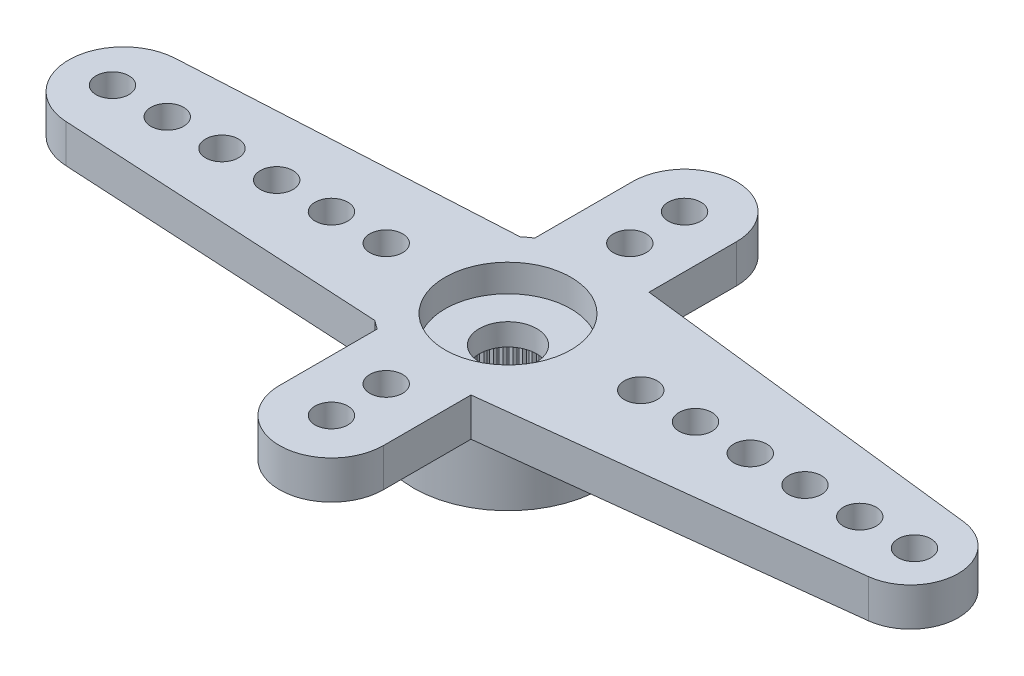
from build123d import *

# Parameters (mm, degrees)
RESSALTO_EXTRUS_O1_DEPTH = 1.4
ESBO_O2_R                = 3.45
RESSALTO_EXTRUS_O2_DEPTH = 2.4
FURO1_D                  = 1.2
PADR_O_LINEAR1_COUNT     = 6
PADR_O_LINEAR1_PITCH     = 2
RESSALTO_EXTRUS_O3_DEPTH = 1.4
FURO2_D                  = 1.2
PADR_O_LINEAR2_COUNT     = 6
PADR_O_LINEAR2_PITCH     = 2
RESSALTO_EXTRUS_O4_DEPTH = 1.4
FURO3_D                  = 1.2
PADR_O_LINEAR3_COUNT     = 2
PADR_O_LINEAR3_PITCH     = 2
PADR_OCIRCULAR1_COUNT    = 2
PADR_OCIRCULAR1_COPY_1_D = 1.2
FURO4_D                  = 4.95
FURO4_DEPTH              = 2
FURO5_D                  = 4.6
FURO5_DEPTH              = 1
FURO6_D                  = 2.1
RESSALTO_EXTRUS_O5_DEPTH = 2
PADR_OCIRCULAR2_COUNT    = 60


with BuildPart() as part:
    # Esboço1 → Ressalto-extrusão1 (new body)
    with BuildSketch(Plane(origin=(0, 0, 0), x_dir=(1, 0, 0), z_dir=(0, 1, 0))):
        with BuildLine():
            Line((-14.159121967, 1.99702088), (-2.209072203, 2.65))
            ThreePointArc((-2.209072203, 2.65), (3.45, 0), (-2.209072203, -2.65))
            Line((-2.209072203, -2.65), (-14.159121967, -1.99702088))
            ThreePointArc((-14.159121967, -1.99702088), (-16.05, 0), (-14.159121967, 1.99702088))
        make_face()
    extrude(amount=-RESSALTO_EXTRUS_O1_DEPTH)

    # Esboço2 → Ressalto-extrusão2 (add)
    with BuildSketch(Plane.XZ.offset(1.4)):
        Circle(ESBO_O2_R)
    extrude(amount=RESSALTO_EXTRUS_O2_DEPTH)

    # Furo1 (through all)
    with Locations(Plane(origin=(0, 0, 0), x_dir=(1, 0, 0), z_dir=(0, 1, 0))):
        with Locations((-14.45, 0)):
            furo1 = Hole(FURO1_D / 2)

    # Padrão linear1: Furo1 ×6
    with Locations(*[(i * PADR_O_LINEAR1_PITCH, 0, 0) for i in range(1, PADR_O_LINEAR1_COUNT)]):
        add(furo1, mode=Mode.SUBTRACT)

    # Esboço12 → Ressalto-extrusão3 (add)
    with BuildSketch(Plane(origin=(0, 0, 0), x_dir=(1, 0, 0), z_dir=(0, 1, 0))):
        with BuildLine():
            Line((0.398979592, 3.426852096), (14.902380952, 1.738258309))
            ThreePointArc((14.902380952, 1.738258309), (16.45, 0), (14.902380952, -1.738258309))
            Line((14.902380952, -1.738258309), (0.398979592, -3.426852096))
            ThreePointArc((0.398979592, -3.426852096), (3.45, 0), (0.398979592, 3.426852096))
        make_face()
    extrude(amount=-RESSALTO_EXTRUS_O3_DEPTH)

    # Furo2 (through all)
    with Locations(Plane(origin=(0, 0, 0), x_dir=(1, 0, 0), z_dir=(0, 1, 0))):
        with Locations((14.85, 0)):
            furo2 = Hole(FURO2_D / 2)

    # Padrão linear2: Furo2 ×6
    with Locations(*[(-i * PADR_O_LINEAR2_PITCH, 0, 0) for i in range(1, PADR_O_LINEAR2_COUNT)]):
        add(furo2, mode=Mode.SUBTRACT)

    # Esboço16 → Ressalto-extrusão4 (add)
    with BuildSketch(Plane(origin=(0, 0, 0), x_dir=(1, 0, 0), z_dir=(0, 1, 0))):
        with BuildLine():
            Line((-1.9, -6.45), (-1.9, 6.45))
            ThreePointArc((-1.9, 6.45), (0, 8.35), (1.9, 6.45))
            Line((1.9, 6.45), (1.9, -6.45))
            ThreePointArc((1.9, -6.45), (0, -8.35), (-1.9, -6.45))
        make_face()
    extrude(amount=-RESSALTO_EXTRUS_O4_DEPTH)

    # Furo3 (through all)
    with Locations(Plane(origin=(0, 0, 0), x_dir=(1, 0, 0), z_dir=(0, 1, 0))):
        with Locations((0, -6.45)):
            furo3 = Hole(FURO3_D / 2)

    # Padrão linear3: Furo3 ×2
    with Locations(*[(0, 0, -i * PADR_O_LINEAR3_PITCH) for i in range(1, PADR_O_LINEAR3_COUNT)]):
        add(furo3, mode=Mode.SUBTRACT)

    # PadrãoCircular1: Furo3 ×2 about axis
    padr_ocircular1_axis = Axis((0, 0, 0), (0, 1, 0))
    for i in range(1, PADR_OCIRCULAR1_COUNT):
        add(furo3.rotate(padr_ocircular1_axis, i * 360 / PADR_OCIRCULAR1_COUNT), mode=Mode.SUBTRACT)

    # PadrãoCircular1 copy 1 (through all)
    with Locations(Plane(origin=(0, 0, 2), x_dir=(-1, 0, 0), z_dir=(0, 1, 0))):
        with Locations((0, -6.45)):
            Hole(PADR_OCIRCULAR1_COPY_1_D / 2)

    # Furo4
    with Locations(Plane(origin=(0, -3.8, 0), x_dir=(-1, 0, 0), z_dir=(0, -1, 0))):
        with Locations((0, 0)):
            Hole(FURO4_D / 2, depth=FURO4_DEPTH)

    # Furo5
    with Locations(Plane(origin=(0, 0, 0), x_dir=(1, 0, 0), z_dir=(0, 1, 0))):
        with Locations((0, 0)):
            Hole(FURO5_D / 2, depth=FURO5_DEPTH)

    # Furo6 (through all)
    with Locations(Plane(origin=(0, 0, 0), x_dir=(1, 0, 0), z_dir=(0, 1, 0))):
        with Locations((0, 0)):
            Hole(FURO6_D / 2)

    # Esboço11 → Ressalto-extrusão5 (add)
    with BuildSketch(Plane.XZ.offset(3.8)):
        with BuildLine():
            Line((-0.098056786, 2.473056786), (0, 2.375))
            Line((0, 2.375), (0.098056786, 2.473056786))
            ThreePointArc((0.098056786, 2.473056786), (0, 2.475), (-0.098056786, 2.473056786))
        make_face()
    ressalto_extrus_o5 = extrude(amount=-RESSALTO_EXTRUS_O5_DEPTH)

    # PadrãoCircular2: Ressalto-extrusão5 ×60 about axis
    padr_ocircular2_axis = Axis((0, 0, 0), (0, 1, 0))
    for i in range(1, PADR_OCIRCULAR2_COUNT):
        add(ressalto_extrus_o5.rotate(padr_ocircular2_axis, i * 360 / PADR_OCIRCULAR2_COUNT))


solid = part.part
